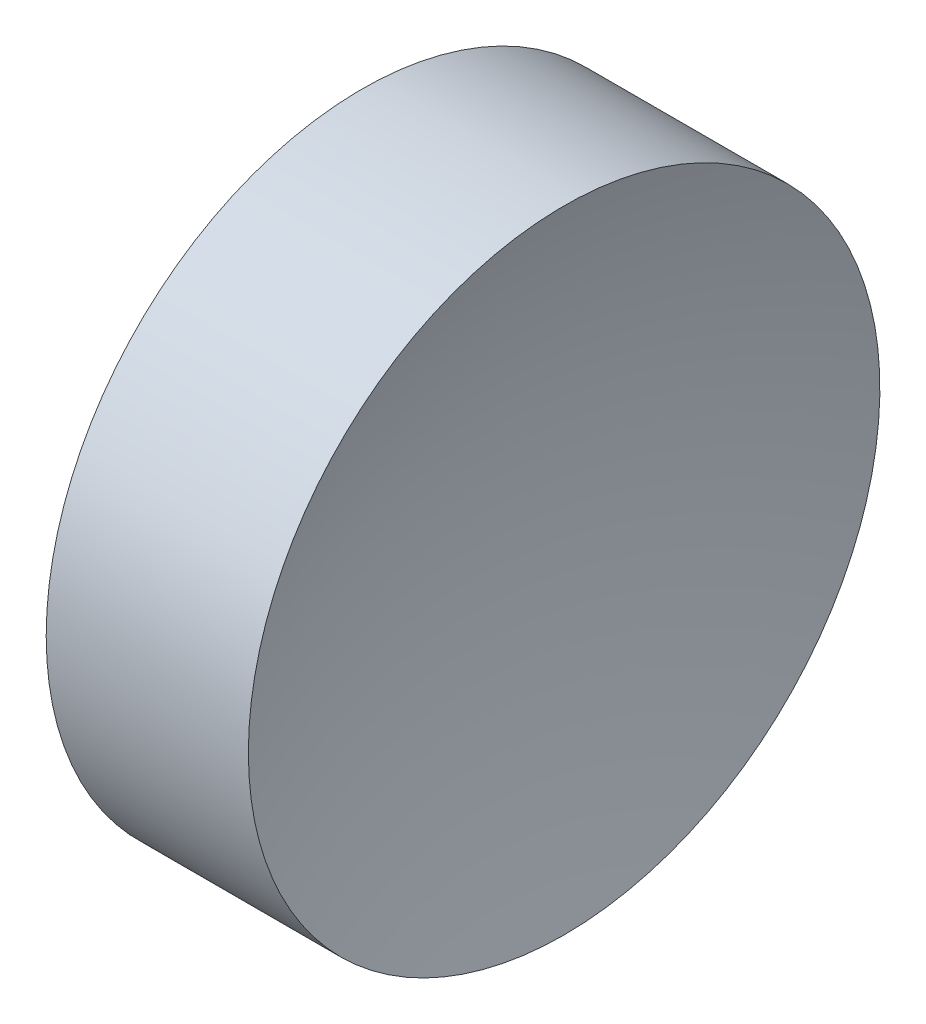
from build123d import *


with BuildPart() as part:
    # 草图1 → 旋转1 (revolve)
    with BuildSketch(Plane.XY, mode=Mode.PRIVATE) as revolve_1_sk:
        with BuildLine():
            Line((115.092655535, 69.378021123), (115.092655535, 81.878021123))
            Line((115.092655535, 81.878021123), (123.095945151, 81.878021123))
            ThreePointArc((123.095945151, 81.878021123), (121.596653108, 75.707775646), (121.092655535, 69.378021123))
            Line((121.092655535, 69.378021123), (115.092655535, 69.378021123))
        make_face()
    revolve(revolve_1_sk.sketch.rotate(Axis((108.985143002, 69.378021123, 0), (1, 0, 0)), 180), axis=Axis((108.985143002, 69.378021123, 0), (1, 0, 0)))  # turned: the seam where the file's is


solid = part.part
